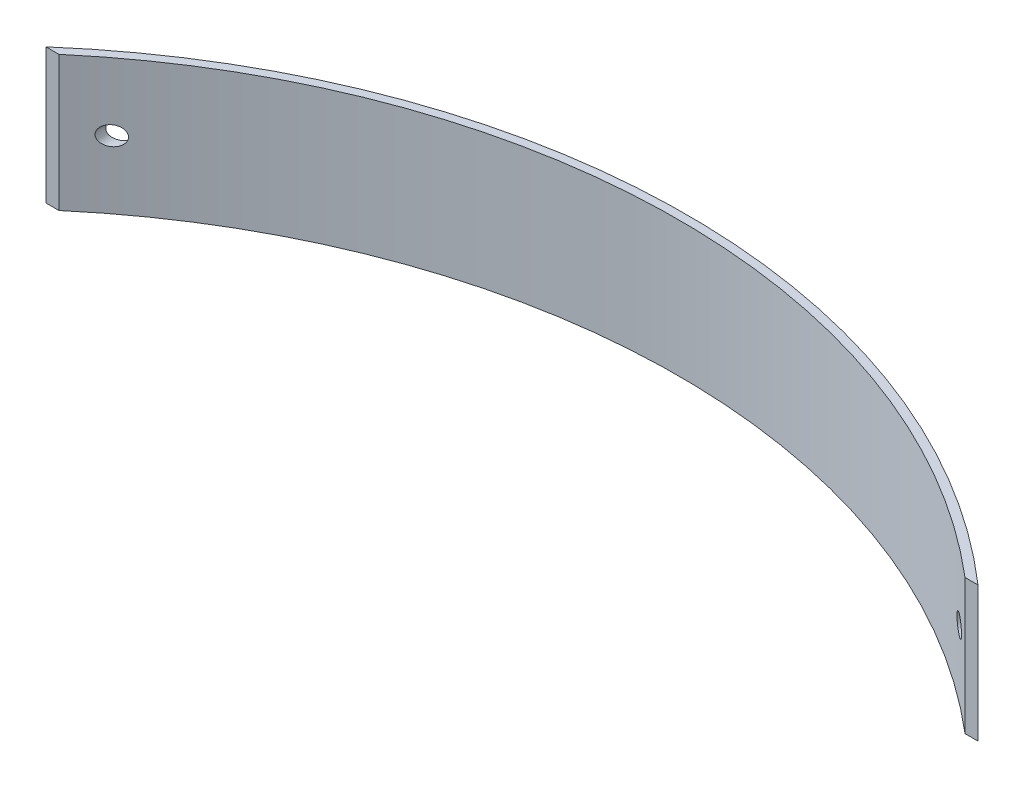
from build123d import *

# Parameters (mm, degrees)
CURVED_PLATE_DEPTH   = 50.8
SKETCH3_R            = 3.5687
MOUNTING_HOLES_DEPTH = 66.75


with BuildPart() as part:
    # Sketch1 → Curved Plate (new body)
    with BuildSketch(Plane(origin=(0, 0, 0), x_dir=(1, 0, 0), z_dir=(0, 1, 0))):
        with BuildLine():
            Line((170.139573777, 0), (175, 0))
            ThreePointArc((175, 0), (0, 65.75), (-175, 0))
            Line((-175, 0), (-170.139573777, 0))
            ThreePointArc((-170.139573777, 0), (0, 62.575), (170.139573777, 0))
        make_face()
    extrude(amount=CURVED_PLATE_DEPTH)

    # Sketch3 → Mounting Holes (cut, through all)
    with BuildSketch(Plane.XY):
        with Locations((-159.125, 25.4)):
            Circle(SKETCH3_R)
        with Locations((159.125, 25.4)):
            Circle(SKETCH3_R)
    extrude(amount=-MOUNTING_HOLES_DEPTH, mode=Mode.SUBTRACT)


solid = part.part
